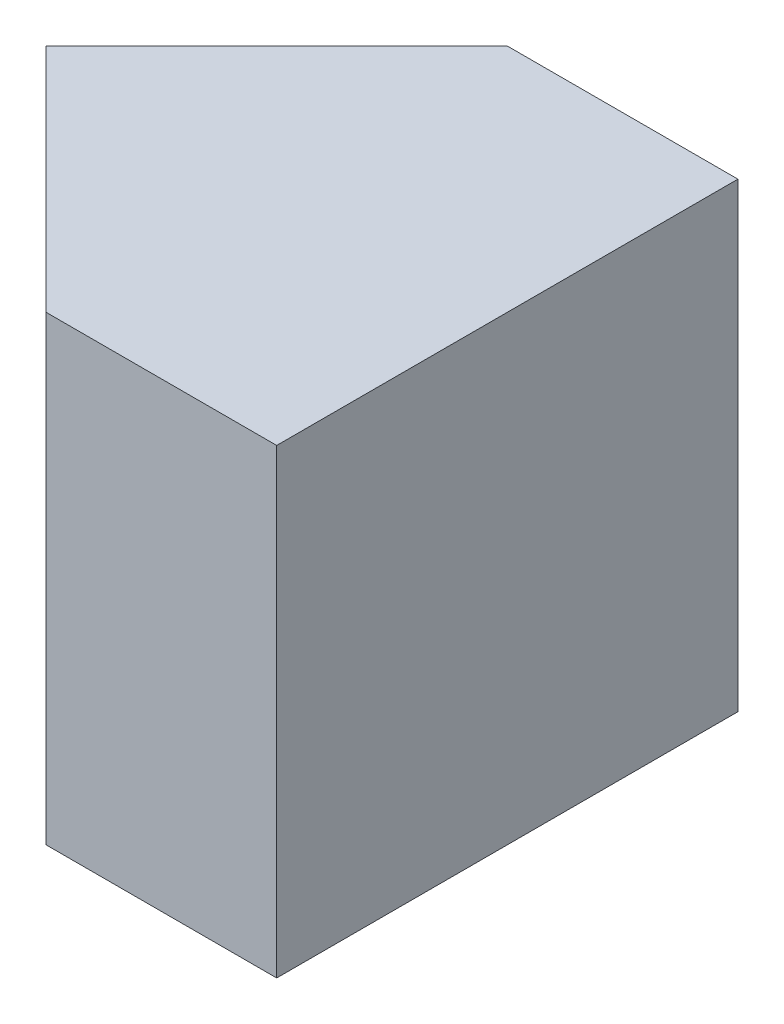
from build123d import *

# Parameters (mm, degrees)
SKETCH1_W           = 20
SKETCH1_H           = 20
BOSS_EXTRUDE1_DEPTH = 20
CUT_EXTRUDE1_DEPTH  = 20
CUT_EXTRUDE2_DEPTH  = 20


with BuildPart() as part:
    # Sketch1 → Boss-Extrude1 (new body)
    with BuildSketch(Plane.XY):
        with Locations((10, 10)):
            Rectangle(SKETCH1_W, SKETCH1_H)
    extrude(amount=BOSS_EXTRUDE1_DEPTH)

    # Sketch2 → Cut-Extrude1 (cut)
    with BuildSketch(Plane(origin=(0, 20, 0), x_dir=(1, 0, 0), z_dir=(0, 1, 0))):
        Polygon((0, 0), (10, 0), (0, -10), align=None)
    extrude(amount=-CUT_EXTRUDE1_DEPTH, mode=Mode.SUBTRACT)

    # Sketch3 → Cut-Extrude2 (cut)
    with BuildSketch(Plane(origin=(0, 20, 0), x_dir=(1, 0, 0), z_dir=(0, 1, 0))):
        Polygon((0, -10), (0, -20), (10, -20), align=None)
    extrude(amount=-CUT_EXTRUDE2_DEPTH, mode=Mode.SUBTRACT)


solid = part.part
